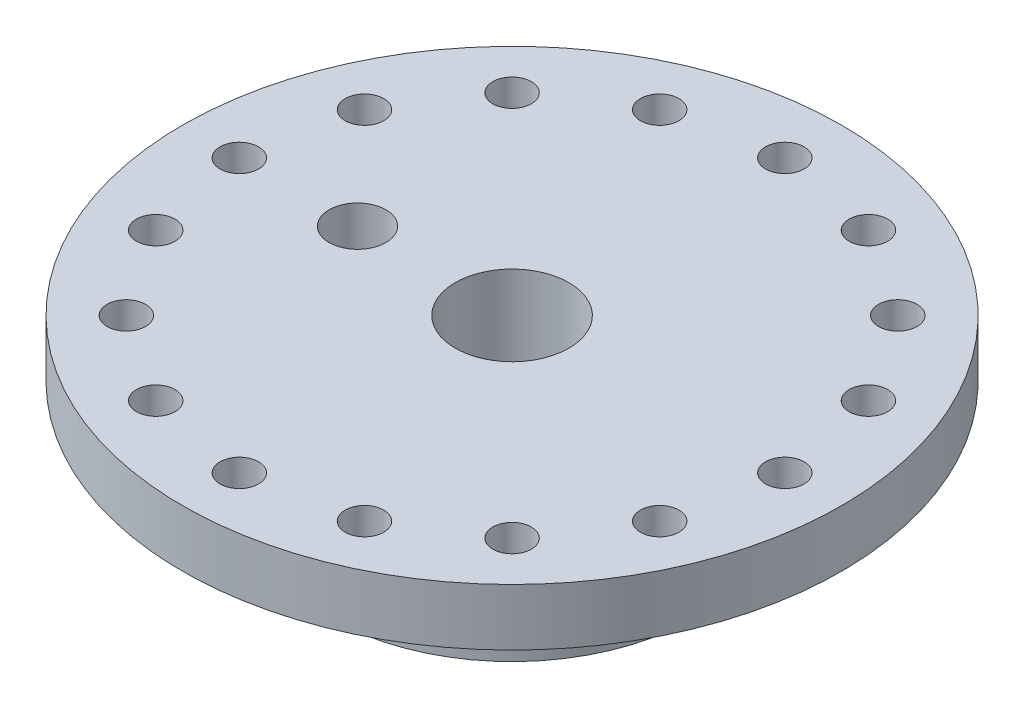
from build123d import *

# Parameters (mm, degrees)
CUT_EXTRUDE1_REACH = 21.05
SKETCH2_R          = 2.15265
SKETCH2_R_2        = 3.175
SKETCH3_R          = 0.396875
CUT_EXTRUDE2_DEPTH = 6.35


with BuildPart() as part:
    # Sketch1 → Revolve1 (revolve)
    with BuildSketch(Plane.XY):
        Polygon((-36.83, 19.05), (-6.35, 19.05), (-6.35, 0), (-20.447, 0), (-20.447, 6.35), (-14.097, 6.35), (-14.097, 12.7), (-36.83, 12.7), align=None)
    revolve(axis=Axis((0, 0, 0), (0, 1, 0)))

    # Sketch2 → Cut-Extrude1 (cut, up to next)
    with BuildSketch(Plane(origin=(0, 19.05, 0), x_dir=(1, 0, 0), z_dir=(0, 1, 0)), mode=Mode.PRIVATE) as cut_extrude1_sk1:
        with Locations((0, 30.48)):
            Circle(SKETCH2_R)
    cut_extrude1_tool1 = extrude(cut_extrude1_sk1.sketch, amount=-CUT_EXTRUDE1_REACH, mode=Mode.PRIVATE) & part.part
    add(cut_extrude1_tool1.solids().sort_by_distance((0, 19.05, -30.48))[0], mode=Mode.SUBTRACT)
    # Sketch2 → Cut-Extrude1 (cut, up to next)
    with BuildSketch(Plane(origin=(0, 19.05, 0), x_dir=(1, 0, 0), z_dir=(0, 1, 0)), mode=Mode.PRIVATE) as cut_extrude1_sk2:
        with Locations((11.664191018, 28.159848151)):
            Circle(SKETCH2_R)
    cut_extrude1_tool2 = extrude(cut_extrude1_sk2.sketch, amount=-CUT_EXTRUDE1_REACH, mode=Mode.PRIVATE) & part.part
    add(cut_extrude1_tool2.solids().sort_by_distance((11.664191, 19.05, -28.159848))[0], mode=Mode.SUBTRACT)
    # Sketch2 → Cut-Extrude1 (cut, up to next)
    with BuildSketch(Plane(origin=(0, 19.05, 0), x_dir=(1, 0, 0), z_dir=(0, 1, 0)), mode=Mode.PRIVATE) as cut_extrude1_sk3:
        with Locations((21.552614691, 21.552614691)):
            Circle(SKETCH2_R)
    cut_extrude1_tool3 = extrude(cut_extrude1_sk3.sketch, amount=-CUT_EXTRUDE1_REACH, mode=Mode.PRIVATE) & part.part
    add(cut_extrude1_tool3.solids().sort_by_distance((21.552615, 19.05, -21.552615))[0], mode=Mode.SUBTRACT)
    # Sketch2 → Cut-Extrude1 (cut, up to next)
    with BuildSketch(Plane(origin=(0, 19.05, 0), x_dir=(1, 0, 0), z_dir=(0, 1, 0)), mode=Mode.PRIVATE) as cut_extrude1_sk4:
        with Locations((28.159848151, 11.664191018)):
            Circle(SKETCH2_R)
    cut_extrude1_tool4 = extrude(cut_extrude1_sk4.sketch, amount=-CUT_EXTRUDE1_REACH, mode=Mode.PRIVATE) & part.part
    add(cut_extrude1_tool4.solids().sort_by_distance((28.159848, 19.05, -11.664191))[0], mode=Mode.SUBTRACT)
    # Sketch2 → Cut-Extrude1 (cut, up to next)
    with BuildSketch(Plane(origin=(0, 19.05, 0), x_dir=(1, 0, 0), z_dir=(0, 1, 0)), mode=Mode.PRIVATE) as cut_extrude1_sk5:
        with Locations((30.48, 0)):
            Circle(SKETCH2_R)
    cut_extrude1_tool5 = extrude(cut_extrude1_sk5.sketch, amount=-CUT_EXTRUDE1_REACH, mode=Mode.PRIVATE) & part.part
    add(cut_extrude1_tool5.solids().sort_by_distance((30.48, 19.05, 0))[0], mode=Mode.SUBTRACT)
    # Sketch2 → Cut-Extrude1 (cut, up to next)
    with BuildSketch(Plane(origin=(0, 19.05, 0), x_dir=(1, 0, 0), z_dir=(0, 1, 0)), mode=Mode.PRIVATE) as cut_extrude1_sk6:
        with Locations((28.159848151, -11.664191018)):
            Circle(SKETCH2_R)
    cut_extrude1_tool6 = extrude(cut_extrude1_sk6.sketch, amount=-CUT_EXTRUDE1_REACH, mode=Mode.PRIVATE) & part.part
    add(cut_extrude1_tool6.solids().sort_by_distance((28.159848, 19.05, 11.664191))[0], mode=Mode.SUBTRACT)
    # Sketch2 → Cut-Extrude1 (cut, up to next)
    with BuildSketch(Plane(origin=(0, 19.05, 0), x_dir=(1, 0, 0), z_dir=(0, 1, 0)), mode=Mode.PRIVATE) as cut_extrude1_sk7:
        with Locations((21.552614691, -21.552614691)):
            Circle(SKETCH2_R)
    cut_extrude1_tool7 = extrude(cut_extrude1_sk7.sketch, amount=-CUT_EXTRUDE1_REACH, mode=Mode.PRIVATE) & part.part
    add(cut_extrude1_tool7.solids().sort_by_distance((21.552615, 19.05, 21.552615))[0], mode=Mode.SUBTRACT)
    # Sketch2 → Cut-Extrude1 (cut, up to next)
    with BuildSketch(Plane(origin=(0, 19.05, 0), x_dir=(1, 0, 0), z_dir=(0, 1, 0)), mode=Mode.PRIVATE) as cut_extrude1_sk8:
        with Locations((11.664191019, -28.159848151)):
            Circle(SKETCH2_R)
    cut_extrude1_tool8 = extrude(cut_extrude1_sk8.sketch, amount=-CUT_EXTRUDE1_REACH, mode=Mode.PRIVATE) & part.part
    add(cut_extrude1_tool8.solids().sort_by_distance((11.664191, 19.05, 28.159848))[0], mode=Mode.SUBTRACT)
    # Sketch2 → Cut-Extrude1 (cut, up to next)
    with BuildSketch(Plane(origin=(0, 19.05, 0), x_dir=(1, 0, 0), z_dir=(0, 1, 0)), mode=Mode.PRIVATE) as cut_extrude1_sk9:
        with Locations((0, -30.48)):
            Circle(SKETCH2_R)
    cut_extrude1_tool9 = extrude(cut_extrude1_sk9.sketch, amount=-CUT_EXTRUDE1_REACH, mode=Mode.PRIVATE) & part.part
    add(cut_extrude1_tool9.solids().sort_by_distance((0, 19.05, 30.48))[0], mode=Mode.SUBTRACT)
    # Sketch2 → Cut-Extrude1 (cut, up to next)
    with BuildSketch(Plane(origin=(0, 19.05, 0), x_dir=(1, 0, 0), z_dir=(0, 1, 0)), mode=Mode.PRIVATE) as cut_extrude1_sk10:
        with Locations((-11.664191018, -28.159848151)):
            Circle(SKETCH2_R)
    cut_extrude1_tool10 = extrude(cut_extrude1_sk10.sketch, amount=-CUT_EXTRUDE1_REACH, mode=Mode.PRIVATE) & part.part
    add(cut_extrude1_tool10.solids().sort_by_distance((-11.664191, 19.05, 28.159848))[0], mode=Mode.SUBTRACT)
    # Sketch2 → Cut-Extrude1 (cut, up to next)
    with BuildSketch(Plane(origin=(0, 19.05, 0), x_dir=(1, 0, 0), z_dir=(0, 1, 0)), mode=Mode.PRIVATE) as cut_extrude1_sk11:
        with Locations((-21.552614691, -21.552614691)):
            Circle(SKETCH2_R)
    cut_extrude1_tool11 = extrude(cut_extrude1_sk11.sketch, amount=-CUT_EXTRUDE1_REACH, mode=Mode.PRIVATE) & part.part
    add(cut_extrude1_tool11.solids().sort_by_distance((-21.552615, 19.05, 21.552615))[0], mode=Mode.SUBTRACT)
    # Sketch2 → Cut-Extrude1 (cut, up to next)
    with BuildSketch(Plane(origin=(0, 19.05, 0), x_dir=(1, 0, 0), z_dir=(0, 1, 0)), mode=Mode.PRIVATE) as cut_extrude1_sk12:
        with Locations((-28.159848151, -11.664191018)):
            Circle(SKETCH2_R)
    cut_extrude1_tool12 = extrude(cut_extrude1_sk12.sketch, amount=-CUT_EXTRUDE1_REACH, mode=Mode.PRIVATE) & part.part
    add(cut_extrude1_tool12.solids().sort_by_distance((-28.159848, 19.05, 11.664191))[0], mode=Mode.SUBTRACT)
    # Sketch2 → Cut-Extrude1 (cut, up to next)
    with BuildSketch(Plane(origin=(0, 19.05, 0), x_dir=(1, 0, 0), z_dir=(0, 1, 0)), mode=Mode.PRIVATE) as cut_extrude1_sk13:
        with Locations((-30.48, 0)):
            Circle(SKETCH2_R)
    cut_extrude1_tool13 = extrude(cut_extrude1_sk13.sketch, amount=-CUT_EXTRUDE1_REACH, mode=Mode.PRIVATE) & part.part
    add(cut_extrude1_tool13.solids().sort_by_distance((-30.48, 19.05, 0))[0], mode=Mode.SUBTRACT)
    # Sketch2 → Cut-Extrude1 (cut, up to next)
    with BuildSketch(Plane(origin=(0, 19.05, 0), x_dir=(1, 0, 0), z_dir=(0, 1, 0)), mode=Mode.PRIVATE) as cut_extrude1_sk14:
        with Locations((-28.159848151, 11.664191018)):
            Circle(SKETCH2_R)
    cut_extrude1_tool14 = extrude(cut_extrude1_sk14.sketch, amount=-CUT_EXTRUDE1_REACH, mode=Mode.PRIVATE) & part.part
    add(cut_extrude1_tool14.solids().sort_by_distance((-28.159848, 19.05, -11.664191))[0], mode=Mode.SUBTRACT)
    # Sketch2 → Cut-Extrude1 (cut, up to next)
    with BuildSketch(Plane(origin=(0, 19.05, 0), x_dir=(1, 0, 0), z_dir=(0, 1, 0)), mode=Mode.PRIVATE) as cut_extrude1_sk15:
        with Locations((-21.552614691, 21.552614691)):
            Circle(SKETCH2_R)
    cut_extrude1_tool15 = extrude(cut_extrude1_sk15.sketch, amount=-CUT_EXTRUDE1_REACH, mode=Mode.PRIVATE) & part.part
    add(cut_extrude1_tool15.solids().sort_by_distance((-21.552615, 19.05, -21.552615))[0], mode=Mode.SUBTRACT)
    # Sketch2 → Cut-Extrude1 (cut, up to next)
    with BuildSketch(Plane(origin=(0, 19.05, 0), x_dir=(1, 0, 0), z_dir=(0, 1, 0)), mode=Mode.PRIVATE) as cut_extrude1_sk16:
        with Locations((-11.664191018, 28.159848151)):
            Circle(SKETCH2_R)
    cut_extrude1_tool16 = extrude(cut_extrude1_sk16.sketch, amount=-CUT_EXTRUDE1_REACH, mode=Mode.PRIVATE) & part.part
    add(cut_extrude1_tool16.solids().sort_by_distance((-11.664191, 19.05, -28.159848))[0], mode=Mode.SUBTRACT)
    # Sketch2 → Cut-Extrude1 (cut, up to next)
    with BuildSketch(Plane(origin=(0, 19.05, 0), x_dir=(1, 0, 0), z_dir=(0, 1, 0)), mode=Mode.PRIVATE) as cut_extrude1_sk17:
        with Locations((-17.272, 0)):
            Circle(SKETCH2_R_2)
    cut_extrude1_tool17 = extrude(cut_extrude1_sk17.sketch, amount=-CUT_EXTRUDE1_REACH, mode=Mode.PRIVATE) & part.part
    add(cut_extrude1_tool17.solids().sort_by_distance((-17.272, 19.05, 0))[0], mode=Mode.SUBTRACT)

    # Sketch3 → Cut-Extrude2 (cut)
    with BuildSketch(Plane.XZ):
        with Locations((0, 16.51)):
            Circle(SKETCH3_R)
        with Locations((3.220941216, 16.192764979)):
            Circle(SKETCH3_R)
        with Locations((6.318103468, 15.253251082)):
            Circle(SKETCH3_R)
        with Locations((9.172464547, 13.727563299)):
            Circle(SKETCH3_R)
        with Locations((11.674332957, 11.674332957)):
            Circle(SKETCH3_R)
        with Locations((13.727563299, 9.172464547)):
            Circle(SKETCH3_R)
        with Locations((15.253251082, 6.318103468)):
            Circle(SKETCH3_R)
        with Locations((16.192764979, 3.220941216)):
            Circle(SKETCH3_R)
        with Locations((16.51, 0)):
            Circle(SKETCH3_R)
        with Locations((16.192764979, -3.220941216)):
            Circle(SKETCH3_R)
        with Locations((15.253251082, -6.318103468)):
            Circle(SKETCH3_R)
        with Locations((13.727563299, -9.172464547)):
            Circle(SKETCH3_R)
        with Locations((11.674332957, -11.674332957)):
            Circle(SKETCH3_R)
        with Locations((9.172464547, -13.727563299)):
            Circle(SKETCH3_R)
        with Locations((6.318103468, -15.253251082)):
            Circle(SKETCH3_R)
        with Locations((3.220941217, -16.192764979)):
            Circle(SKETCH3_R)
        with Locations((0, -16.51)):
            Circle(SKETCH3_R)
        with Locations((-3.220941216, -16.192764979)):
            Circle(SKETCH3_R)
        with Locations((-6.318103468, -15.253251082)):
            Circle(SKETCH3_R)
        with Locations((-9.172464547, -13.727563299)):
            Circle(SKETCH3_R)
        with Locations((-11.674332957, -11.674332957)):
            Circle(SKETCH3_R)
        with Locations((-13.727563299, -9.172464547)):
            Circle(SKETCH3_R)
        with Locations((-15.253251082, -6.318103468)):
            Circle(SKETCH3_R)
        with Locations((-16.192764979, -3.220941216)):
            Circle(SKETCH3_R)
        with Locations((-16.51, 0)):
            Circle(SKETCH3_R)
        with Locations((-16.192764979, 3.220941216)):
            Circle(SKETCH3_R)
        with Locations((-15.253251082, 6.318103468)):
            Circle(SKETCH3_R)
        with Locations((-13.727563299, 9.172464547)):
            Circle(SKETCH3_R)
        with Locations((-11.674332957, 11.674332957)):
            Circle(SKETCH3_R)
        with Locations((-9.172464547, 13.727563299)):
            Circle(SKETCH3_R)
        with Locations((-6.318103468, 15.253251082)):
            Circle(SKETCH3_R)
        with Locations((-3.220941216, 16.192764979)):
            Circle(SKETCH3_R)
    extrude(amount=-CUT_EXTRUDE2_DEPTH, mode=Mode.SUBTRACT)


solid = part.part
